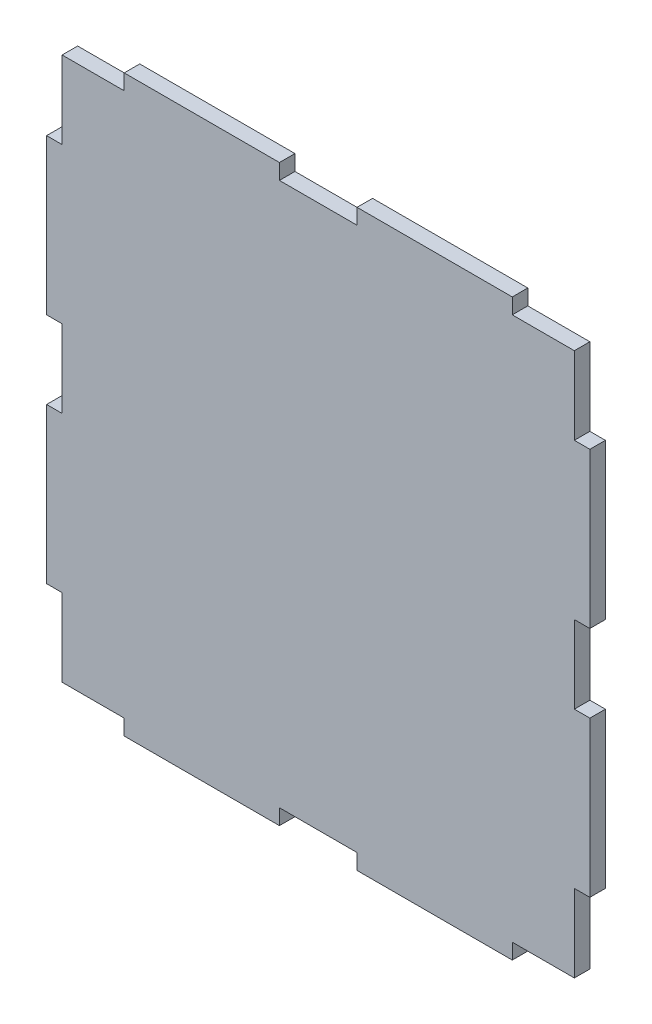
from build123d import *

# Parameters (mm, degrees)
SKETCH1_W           = 66
SKETCH1_H           = 70
BOSS_EXTRUDE1_DEPTH = 2
SKETCH2_W           = 2
SKETCH2_H           = 20
BOSS_EXTRUDE2_DEPTH = 2
SKETCH3_W           = 20
SKETCH3_H           = 2
BOSS_EXTRUDE3_DEPTH = 2


with BuildPart() as part:
    # Sketch1 → Boss-Extrude1 (new body)
    with BuildSketch(Plane.XY):
        Rectangle(SKETCH1_W, SKETCH1_H)
    extrude(amount=BOSS_EXTRUDE1_DEPTH)

    # Sketch2 → Boss-Extrude2 (add)
    with BuildSketch(Plane(origin=(0, 0, 0), x_dir=(-1, 0, 0), z_dir=(0, 0, -1))):
        with Locations((34, -15)):
            Rectangle(SKETCH2_W, SKETCH2_H)
        with Locations((34, 15)):
            Rectangle(SKETCH2_W, SKETCH2_H)
        with Locations((-34, -15)):
            Rectangle(SKETCH2_W, SKETCH2_H)
        with Locations((-34, 15)):
            Rectangle(SKETCH2_W, SKETCH2_H)
    extrude(amount=-BOSS_EXTRUDE2_DEPTH)

    # Sketch3 → Boss-Extrude3 (add)
    with BuildSketch(Plane(origin=(0, 0, 0), x_dir=(-1, 0, 0), z_dir=(0, 0, -1))):
        with Locations((-15, 36)):
            Rectangle(SKETCH3_W, SKETCH3_H)
        with Locations((15, 36)):
            Rectangle(SKETCH3_W, SKETCH3_H)
        with Locations((-15, -36)):
            Rectangle(SKETCH3_W, SKETCH3_H)
        with Locations((15, -36)):
            Rectangle(SKETCH3_W, SKETCH3_H)
    extrude(amount=-BOSS_EXTRUDE3_DEPTH)


solid = part.part
